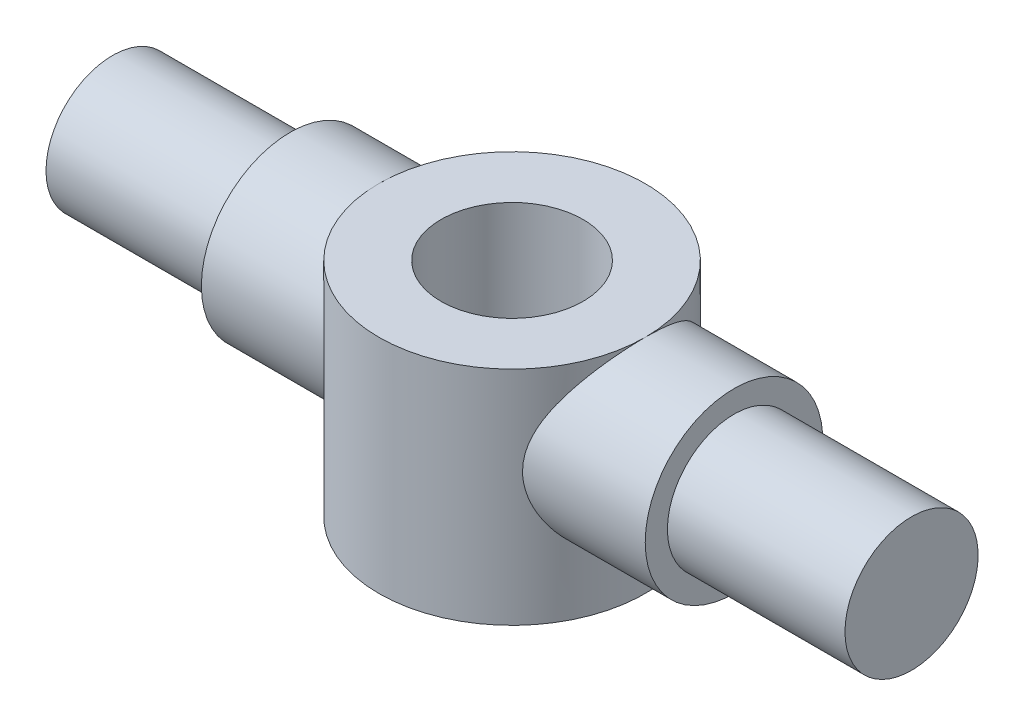
from build123d import *

# Parameters (mm, degrees)
BOSS_EXTRUDE1_DEPTH      = 2
BOSS_EXTRUDE1_DEPTH_BACK = 3
SKETCH1_5_R              = 3
SKETCH1_5_R_2            = 1.6


with BuildPart() as part:
    # Sketch1 → Revolve2 (revolve)
    with BuildSketch(Plane(origin=(0, 0, 0), x_dir=(1, 0, 0), z_dir=(0, 1, 0))):
        Polygon((-5, -1.5), (-5, -2), (-2.236067977, -2), (-2.236067977, 0), (-9, 0), (-9, -1.5), align=None)
        Polygon((9, 0), (2.236067977, 0), (2.236067977, -2), (5, -2), (5, -1.5), (9, -1.5), align=None)
    revolve(axis=Axis((-9, 0, 0), (1, 0, 0)))

    # Sketch1_5 → Boss-Extrude1 (add, two sides: drawn at the far end of the back side and taken through both)
    with BuildSketch(Plane(origin=(0, 0, 0), x_dir=(1, 0, 0), z_dir=(0, 1, 0)).offset(-BOSS_EXTRUDE1_DEPTH_BACK)):
        Circle(SKETCH1_5_R)
        Circle(SKETCH1_5_R_2, mode=Mode.SUBTRACT)
    extrude(amount=BOSS_EXTRUDE1_DEPTH + BOSS_EXTRUDE1_DEPTH_BACK)


solid = part.part
